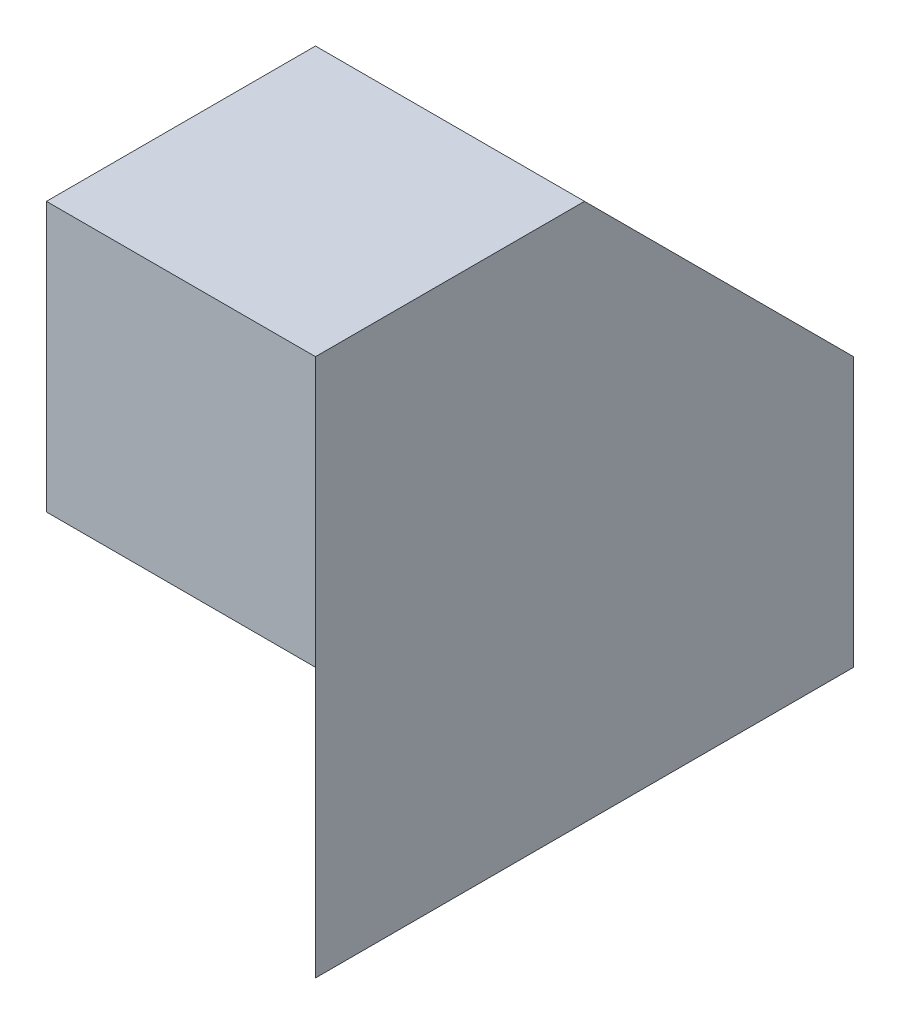
from build123d import *

# Parameters (mm, degrees)
SKETCH1_W           = 40
SKETCH1_H           = 20
BOSS_EXTRUDE1_DEPTH = 40
CUT_EXTRUDE1_DEPTH  = 40
SKETCH3_W           = 40
SKETCH3_H           = 20
BOSS_EXTRUDE2_DEPTH = 20
CUT_EXTRUDE2_DEPTH  = 20


with BuildPart() as part:
    # Sketch1 → Boss-Extrude1 (new body)
    with BuildSketch(Plane.XY):
        with Locations((20, 10)):
            Rectangle(SKETCH1_W, SKETCH1_H)
    extrude(amount=BOSS_EXTRUDE1_DEPTH)

    # Sketch2 → Cut-Extrude1 (cut)
    with BuildSketch(Plane(origin=(0, 20, 0), x_dir=(1, 0, 0), z_dir=(0, 1, 0))):
        Polygon((0, 0), (40, -40), (0, -40), align=None)
    extrude(amount=-CUT_EXTRUDE1_DEPTH, mode=Mode.SUBTRACT)

    # Sketch3 → Boss-Extrude2 (add)
    with BuildSketch(Plane(origin=(40, 0, 0), x_dir=(0, 0, -1), z_dir=(1, 0, 0))):
        with Locations((-20, 30)):
            Rectangle(SKETCH3_W, SKETCH3_H)
    extrude(amount=-BOSS_EXTRUDE2_DEPTH)

    # Sketch4 → Cut-Extrude2 (cut)
    with BuildSketch(Plane.ZY.offset(-20)):
        Polygon((0, 20), (20, 40), (0, 40), align=None)
    extrude(amount=-CUT_EXTRUDE2_DEPTH, mode=Mode.SUBTRACT)


solid = part.part
